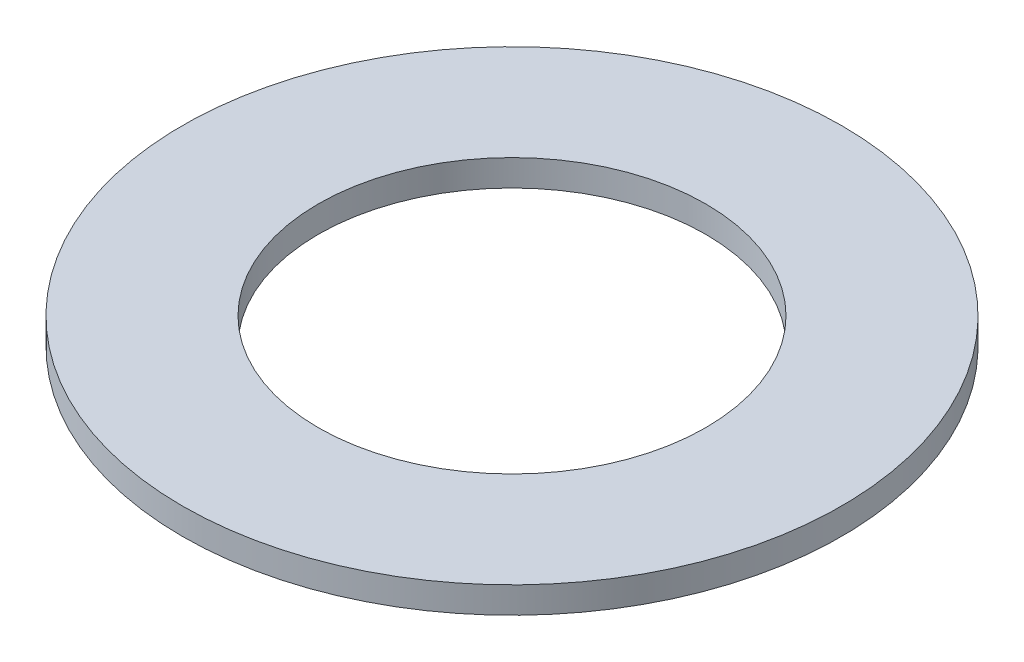
from build123d import *

# Parameters (mm, degrees)
SKETCH1_R           = 12.5
SKETCH1_R_2         = 7.35
BOSS_EXTRUDE1_DEPTH = 1


with BuildPart() as part:
    # Sketch1 → Boss-Extrude1 (new body)
    with BuildSketch(Plane(origin=(0, 0, 0), x_dir=(1, 0, 0), z_dir=(0, 1, 0))):
        Circle(SKETCH1_R)
        Circle(SKETCH1_R_2, mode=Mode.SUBTRACT)
    extrude(amount=BOSS_EXTRUDE1_DEPTH)


solid = part.part
